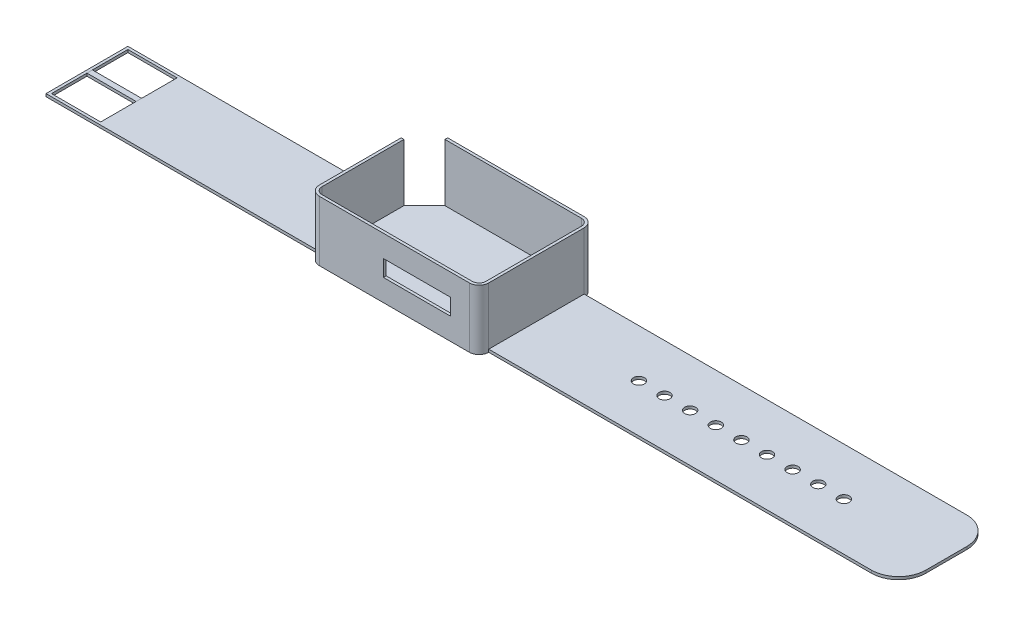
from build123d import *

# Parameters (mm, degrees)
SKETCH1_W           = 22.5
SKETCH1_H           = 1
BOSS_EXTRUDE1_DEPTH = 22
SHELL1_T            = -1
CUT_EXTRUDE1_DEPTH  = 21
BOSS_EXTRUDE2_DEPTH = 100
SKETCH3_W           = 34.928932188
SKETCH3_H           = 1
BOSS_EXTRUDE3_DEPTH = 150
CUT_EXTRUDE2_DEPTH  = 10
SKETCH5_R           = 2.004611179
SKETCH5_R_2         = 2
CUT_EXTRUDE3_DEPTH  = 10
FILLET1_R           = 10
FILLET2_R           = 10
CUT_EXTRUDE4_DEPTH  = 10
BOSS_EXTRUDE5_DEPTH = 18


with BuildPart() as part:
    # Sketch1 → Boss-Extrude1 (new body)
    with BuildSketch(Plane(origin=(0, 0, 0), x_dir=(1, 0, 0), z_dir=(0, 1, 0))):
        with Locations((-27.442029657, 22.648486015)):
            Rectangle(SKETCH1_W, SKETCH1_H)
        with BuildLine():
            Line((-16.192029657, 23.148486015), (-16.192029657, 22.148486015))
            Line((-16.192029657, 22.148486015), (10.272436437, 22.148486015))
            ThreePointArc((10.272436437, 22.148486015), (12.772436437, 21.112952109), (13.807970343, 18.612952109))
            Line((13.807970343, 18.612952109), (13.807970343, -14.315980079))
            ThreePointArc((13.807970343, -14.315980079), (12.772436437, -16.815980079), (10.272436437, -17.851513985))
            Line((10.272436437, -17.851513985), (-16.192029657, -17.851513985))
            Line((-16.192029657, -17.851513985), (-16.192029657, -18.851513985))
            Line((-16.192029657, -18.851513985), (11.272436437, -18.851513985))
            ThreePointArc((11.272436437, -18.851513985), (13.772436437, -17.815980079), (14.807970343, -15.315980079))
            Line((14.807970343, -15.315980079), (14.807970343, -14.315980079))
            Line((14.807970343, -14.315980079), (14.807970343, 19.612952109))
            ThreePointArc((14.807970343, 19.612952109), (13.772436437, 22.112952109), (11.272436437, 23.148486015))
            Line((11.272436437, 23.148486015), (-16.192029657, 23.148486015))
        make_face()
        with BuildLine():
            Line((-46.192029657, -14.315980079), (-46.192029657, 14.648486015))
            Line((-46.192029657, 14.648486015), (-47.192029657, 14.648486015))
            Line((-47.192029657, 14.648486015), (-47.192029657, -15.315980079))
            ThreePointArc((-47.192029657, -15.315980079), (-46.156495751, -17.815980079), (-43.656495751, -18.851513985))
            Line((-43.656495751, -18.851513985), (-16.192029657, -18.851513985))
            Line((-16.192029657, -18.851513985), (-16.192029657, -17.851513985))
            Line((-16.192029657, -17.851513985), (-42.656495751, -17.851513985))
            ThreePointArc((-42.656495751, -17.851513985), (-45.156495751, -16.815980079), (-46.192029657, -14.315980079))
        make_face()
        with BuildLine():
            Line((-42.656495751, -17.851513985), (10.272436437, -17.851513985))
            ThreePointArc((10.272436437, -17.851513985), (12.772436437, -16.815980079), (13.807970343, -14.315980079))
            Line((13.807970343, -14.315980079), (13.807970343, 18.612952109))
            ThreePointArc((13.807970343, 18.612952109), (12.772436437, 21.112952109), (10.272436437, 22.148486015))
            Line((10.272436437, 22.148486015), (-38.692029657, 22.148486015))
            Line((-38.692029657, 22.148486015), (-46.192029657, 14.648486015))
            Line((-46.192029657, 14.648486015), (-46.192029657, -14.315980079))
            ThreePointArc((-46.192029657, -14.315980079), (-45.156495751, -16.815980079), (-42.656495751, -17.851513985))
        make_face()
    extrude(amount=BOSS_EXTRUDE1_DEPTH)

    # Shell1
    shell1_openings = [part.faces().sort_by_distance(p)[0] for p in [
        (-15.741951125, 22, -1.860810616),
    ]]
    offset(amount=SHELL1_T, openings=shell1_openings, kind=Kind.INTERSECTION)

    # Sketch2 → Cut-Extrude1 (cut)
    with BuildSketch(Plane(origin=(0, 22, 0), x_dir=(1, 0, 0), z_dir=(0, 1, 0))):
        Polygon((-38.692029657, 22.148486015), (-37.692029657, 22.148486015), (-37.692029657, 21.734272453), (-45.777816094, 13.648486015), (-46.192029657, 13.648486015), (-46.192029657, 14.648486015), align=None)
    extrude(amount=-CUT_EXTRUDE1_DEPTH, mode=Mode.SUBTRACT)

    # 3DSketch2 → Boss-Extrude2 (add)
    with BuildSketch(Plane(origin=(-47.192029657, 1.000281881, -14.648486015), x_dir=(0, -0.03336368478911428, 0.9994432772985632), z_dir=(-1, 0, 0))):
        Polygon((0, 0), (29.947784196, 0.999725002), (29.981157285, 0), (0.033373089, -0.999725002), align=None)
    extrude(amount=BOSS_EXTRUDE2_DEPTH)

    # Sketch3 → Boss-Extrude3 (add)
    with BuildSketch(Plane(origin=(14.807970343, 0, 0), x_dir=(0, 0, -1), z_dir=(1, 0, 0))):
        with Locations((2.148486015, 0.5)):
            Rectangle(SKETCH3_W, SKETCH3_H)
    extrude(amount=BOSS_EXTRUDE3_DEPTH)

    # Sketch4 → Cut-Extrude2 (cut)
    with BuildSketch(Plane.XY.offset(18.851513985)):
        Polygon((4.406319914, 11), (4.406319914, 14), (-16.192029657, 14), (-20.192029657, 14), (-20.192029657, 8), (-16.192029657, 8), (4.406319914, 8), align=None)
    extrude(amount=-CUT_EXTRUDE2_DEPTH, mode=Mode.SUBTRACT)

    # Sketch5 → Cut-Extrude3 (cut)
    with BuildSketch(Plane(origin=(0, 1.000281881, 0), x_dir=(1, 0, 0), z_dir=(0, 1, 0))):
        with Locations(Location((127.307970343, 2.148486015, 0), (0, 0, 270))):
            Circle(SKETCH5_R)
        with Locations(Location((108.557970343, 2.148486015, 0), (0, 0, 270))):
            Circle(SKETCH5_R_2)
        with Locations(Location((89.807970343, 2.148486015, 0), (0, 0, 270))):
            Circle(SKETCH5_R_2)
        with Locations(Location((71.057970343, 2.148486015, 0), (0, 0, 270))):
            Circle(SKETCH5_R_2)
        with Locations(Location((52.307970343, 2.148486015, 0), (0, 0, 270))):
            Circle(SKETCH5_R_2)
        with Locations(Location((61.682970343, 2.148486015, 0), (0, 0, 270))):
            Circle(SKETCH5_R_2)
        with Locations(Location((117.932970343, 2.148486015, 0), (0, 0, 270))):
            Circle(SKETCH5_R_2)
        with Locations(Location((99.182970343, 2.148486015, 0), (0, 0, 270))):
            Circle(SKETCH5_R_2)
        with Locations(Location((80.432970343, 2.148486015, 0), (0, 0, 270))):
            Circle(SKETCH5_R_2)
    extrude(amount=-CUT_EXTRUDE3_DEPTH, mode=Mode.SUBTRACT)

    # Fillet1
    fillet1_edges = [part.edges().sort_by_distance(p)[0] for p in [
        (164.807970343, 0.5, -19.612952109),
    ]]
    fillet(fillet1_edges, radius=FILLET1_R)

    # Fillet2
    fillet2_edges = [part.edges().sort_by_distance(p)[0] for p in [
        (164.807970343, 0.5, 15.315980079),
    ]]
    fillet(fillet2_edges, radius=FILLET2_R)

    # Sketch6 → Cut-Extrude4 (cut)
    with BuildSketch(Plane(origin=(0, 1.000281881, 0), x_dir=(1, 0, 0), z_dir=(0, 1, 0))):
        Polygon((-137.192029657, 13.648486015), (-128.192029657, 13.648486015), (-128.192029657, -14.315980079), (-146.192029657, -14.315980079), (-146.192029657, 13.648486015), align=None)
    extrude(amount=-CUT_EXTRUDE4_DEPTH, mode=Mode.SUBTRACT)


with BuildPart() as body_2:
    # Sketch7 → Boss-Extrude5 (new body)
    with BuildSketch(Plane.ZY.offset(128.192029657)):
        Polygon((1.333747032, 0.500140941), (1.333747032, 1.000281881), (-0.666252968, 1.000281881), (-0.666252968, 0), (1.333747032, 0), align=None)
    extrude(amount=BOSS_EXTRUDE5_DEPTH)


solid = Compound([part.part, body_2.part])
